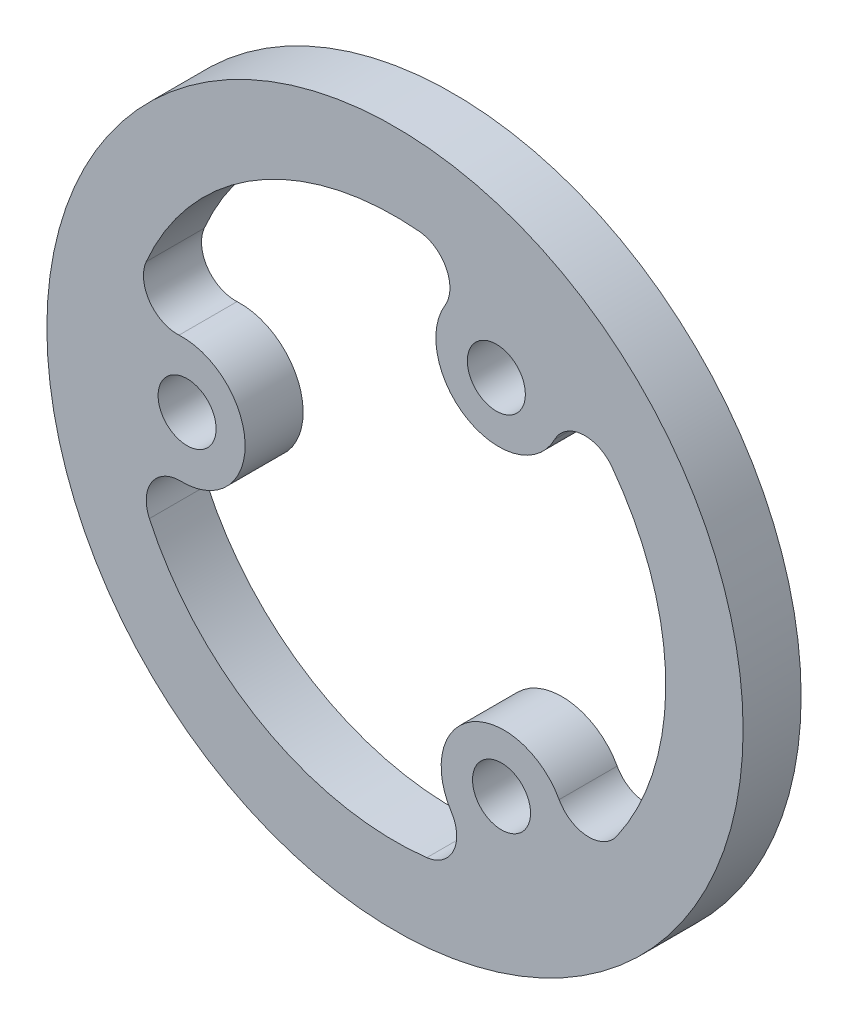
from build123d import *

# Parameters (mm, degrees)
ESQUISSE1_R        = 18
ESQUISSE1_R_2      = 1.5
BOSS_EXTRU_1_DEPTH = 3


with BuildPart() as part:
    # Esquisse1 → Boss.-Extru.1 (new body)
    with BuildSketch(Plane.XY):
        Circle(ESQUISSE1_R)
        with Locations((5.240453276, 9.386167986)):
            Circle(ESQUISSE1_R_2, mode=Mode.SUBTRACT)
        with Locations((5.508433282, -9.231449657)):
            Circle(ESQUISSE1_R_2, mode=Mode.SUBTRACT)
        with Locations((-10.748886558, -0.154718329)):
            Circle(ESQUISSE1_R_2, mode=Mode.SUBTRACT)
        with BuildLine():
            ThreePointArc((11.453630047, -8.050736534), (13.998549936, 0.201493638), (11.217170127, 8.377057619))
            ThreePointArc((11.217170127, 8.377057619), (9.667160345, 9.073667479), (8.256579008, 8.126009358))
            ThreePointArc((8.256579008, 8.126009358), (3.778001199, 6.766772269), (2.58509342, 11.292493835))
            ThreePointArc((2.58509342, 11.292493835), (2.651653429, 12.990541357), (1.245327334, 13.944502853))
            ThreePointArc((1.245327334, 13.944502853), (-7.173773577, 12.022353042), (-12.86332977, 5.525825479))
            ThreePointArc((-12.86332977, 5.525825479), (-12.691606715, 3.835172702), (-11.165620039, 3.087402491))
            ThreePointArc((-11.165620039, 3.087402491), (-7.749197286, -0.111541121), (-11.072133243, -3.407490345))
            ThreePointArc((-11.072133243, -3.407490345), (-12.575965538, -4.198871447), (-12.698957381, -5.893766319))
            ThreePointArc((-12.698957381, -5.893766319), (-6.824776359, -12.22384668), (1.646159643, -13.902883098))
            ThreePointArc((1.646159643, -13.902883098), (3.02444637, -12.90884018), (2.909041031, -11.213411848))
            ThreePointArc((2.909041031, -11.213411848), (3.971196087, -6.655231148), (8.487039823, -7.88500349))
            ThreePointArc((8.487039823, -7.88500349), (9.92431211, -8.79166991), (11.453630047, -8.050736534))
        make_face(mode=Mode.SUBTRACT)
    extrude(amount=BOSS_EXTRU_1_DEPTH)


solid = part.part
